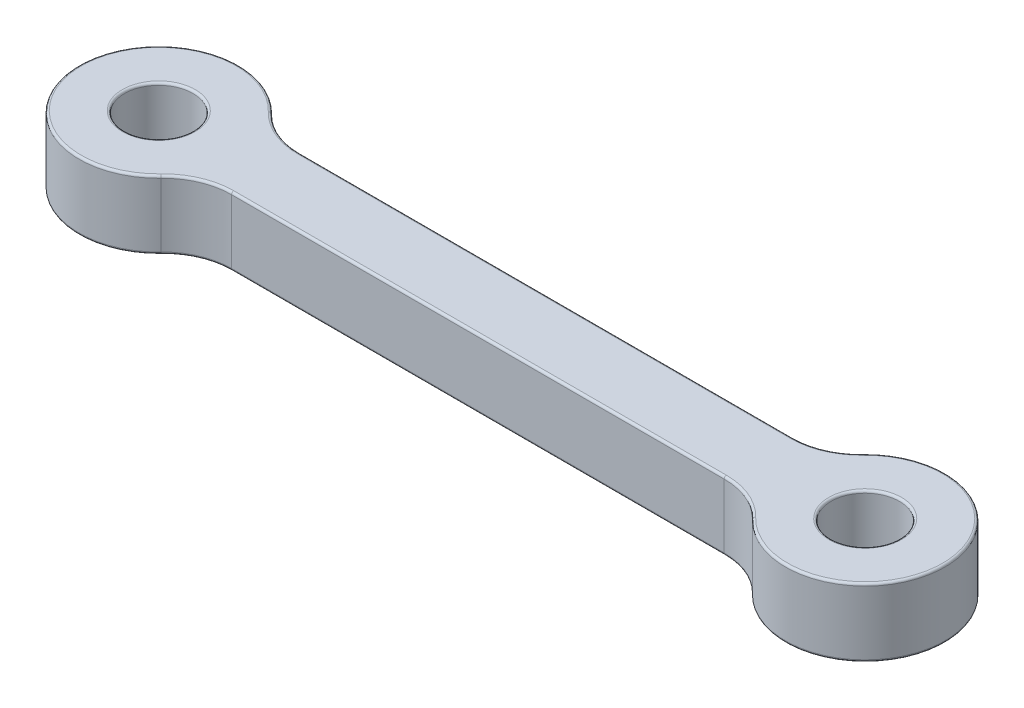
from build123d import *

# Parameters (mm, degrees)
SKETCH1_R           = 1.5
BOSS_EXTRUDE1_DEPTH = 3
FILLET1_R           = 0.1


with BuildPart() as part:
    # Sketch1 → Boss-Extrude1 (new body)
    with BuildSketch(Plane(origin=(0, 0, 0), x_dir=(1, 0, 0), z_dir=(0, 1, 0))):
        with BuildLine():
            Line((4.69041576, 1.5), (26.30958424, 1.5))
            ThreePointArc((26.30958424, 1.5), (27.486281051, 1.740401367), (28.474391514, 2.423076923))
            ThreePointArc((28.474391514, 2.423076923), (34.5, 0), (28.474391514, -2.423076923))
            ThreePointArc((28.474391514, -2.423076923), (27.486281051, -1.740401367), (26.30958424, -1.5))
            Line((26.30958424, -1.5), (4.69041576, -1.5))
            ThreePointArc((4.69041576, -1.5), (3.513718949, -1.740401367), (2.525608486, -2.423076923))
            ThreePointArc((2.525608486, -2.423076923), (-3.5, 0), (2.525608486, 2.423076923))
            ThreePointArc((2.525608486, 2.423076923), (3.513718949, 1.740401367), (4.69041576, 1.5))
        make_face()
        Circle(SKETCH1_R, mode=Mode.SUBTRACT)
        with Locations((31, 0)):
            Circle(SKETCH1_R, mode=Mode.SUBTRACT)
    extrude(amount=BOSS_EXTRUDE1_DEPTH)

    # Fillet1
    fillet1_edges = [part.edges().sort_by_distance(p)[0] for p in [
        (27.486281051, 0, -1.740401367),
        (34.5, 0, 0),
        (29.5, 3, 0),
        (27.486281051, 0, 1.740401367),
        (15.5, 0, 1.5),
        (3.513718949, 0, 1.740401367),
        (-3.5, 0, 0),
        (3.513718949, 0, -1.740401367),
        (15.5, 0, -1.5),
        (29.5, 0, 0),
        (-1.5, 0, 0),
        (15.5, 3, -1.5),
        (3.513718949, 3, -1.740401367),
        (-3.5, 3, 0),
        (3.513718949, 3, 1.740401367),
        (15.5, 3, 1.5),
        (27.486281051, 3, 1.740401367),
        (34.5, 3, 0),
        (27.486281051, 3, -1.740401367),
        (-1.5, 3, 0),
    ]]
    fillet(fillet1_edges, radius=FILLET1_R)


solid = part.part
